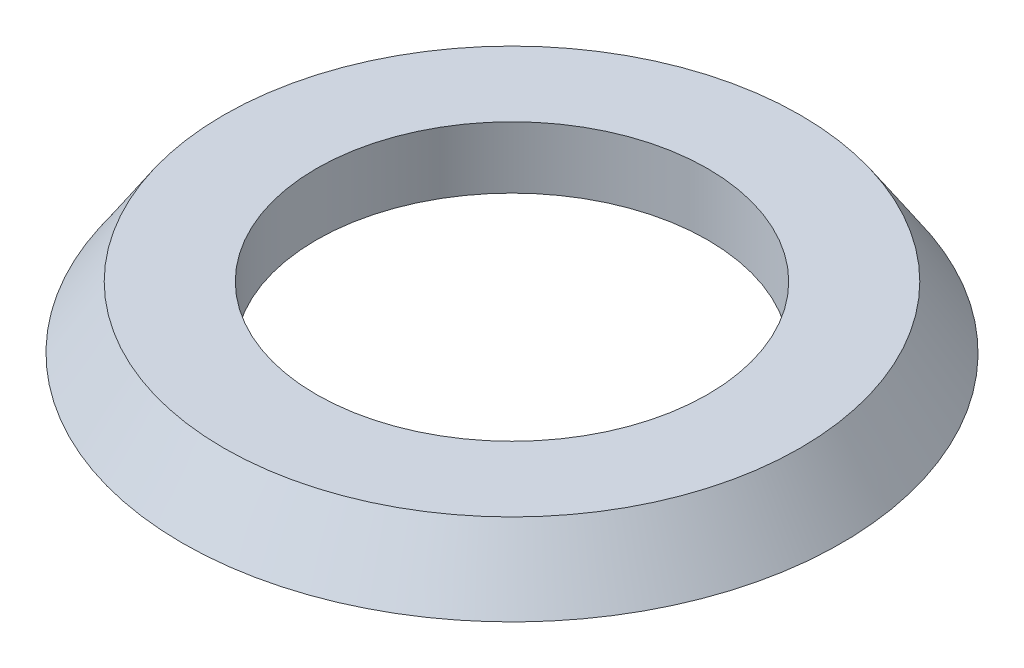
from build123d import *

# Parameters (mm, degrees)
SKETCH_2_R          = 9.5
CUT_EXTRUDE_1_DEPTH = 10


with BuildPart() as part:
    # 草图1 → 旋转1 (revolve)
    with BuildSketch(Plane.XY):
        Polygon((0, 0), (0, 3), (14, 3), (16, 0), align=None)
    revolve(axis=Axis((0, 0, 0), (0, 1, 0)))

    # 草图2 → 切除-拉伸1 (cut)
    with BuildSketch(Plane(origin=(0, 3, 0), x_dir=(1, 0, 0), z_dir=(0, 1, 0))):
        Circle(SKETCH_2_R)
    extrude(amount=-CUT_EXTRUDE_1_DEPTH, mode=Mode.SUBTRACT)


solid = part.part
